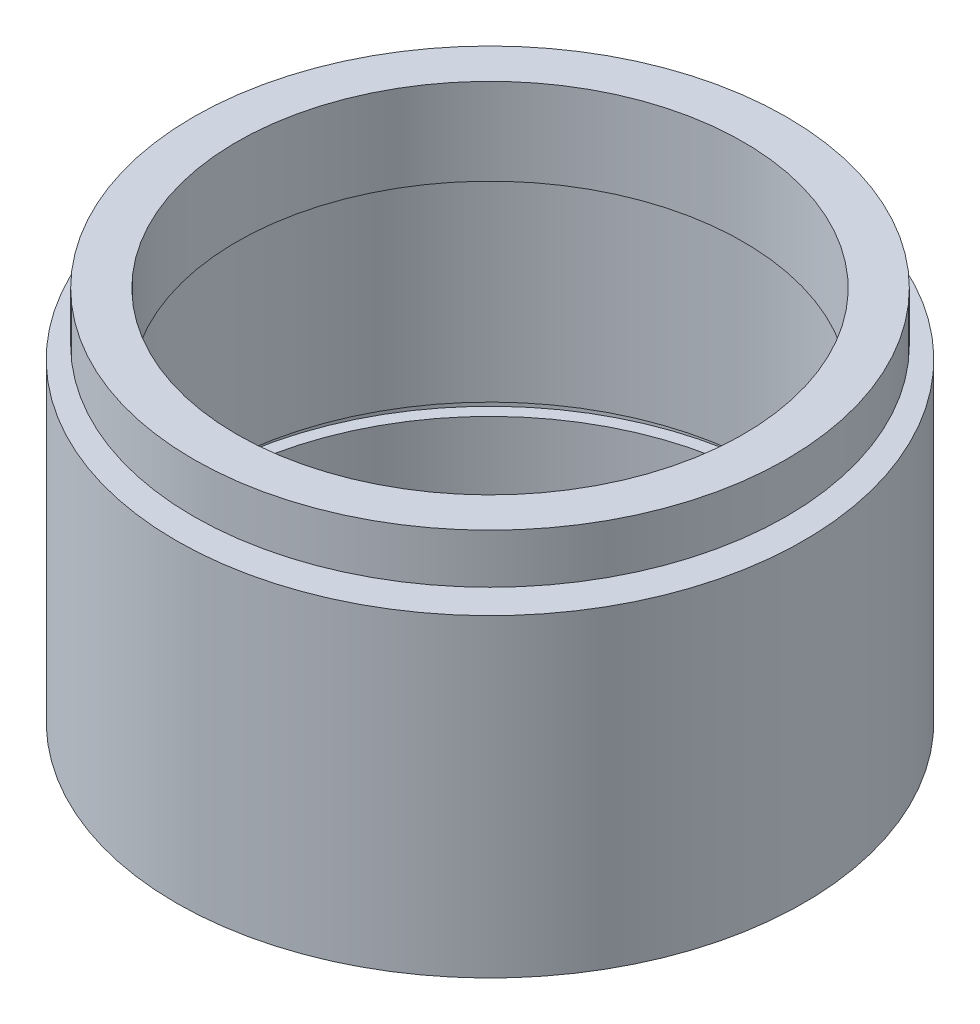
from build123d import *


with BuildPart() as part:
    # 草图1 → 旋转1 (revolve)
    with BuildSketch(Plane.XY, mode=Mode.PRIVATE) as revolve_1_sk:
        Polygon((22.5, 22.4), (24, 22.4), (24, 23.4), (20.5, 23.4), (20.5, 30.4), (24, 30.4), (24, 26.4), (22.5, 26.4), (22.5, 25.4), (23.5, 25.4), (25.4, 25.4), (25.4, 0), (22.5, 0), (22.5, 5.5), (23.5, 5.5), (23.5, 6.5), (22.5, 6.5), align=None)
    revolve(revolve_1_sk.sketch.rotate(Axis((0, 161.376166943, 0), (0, -1, 0)), 90), axis=Axis((0, 161.376166943, 0), (0, -1, 0)))  # turned: the seam where the file's is


solid = part.part
